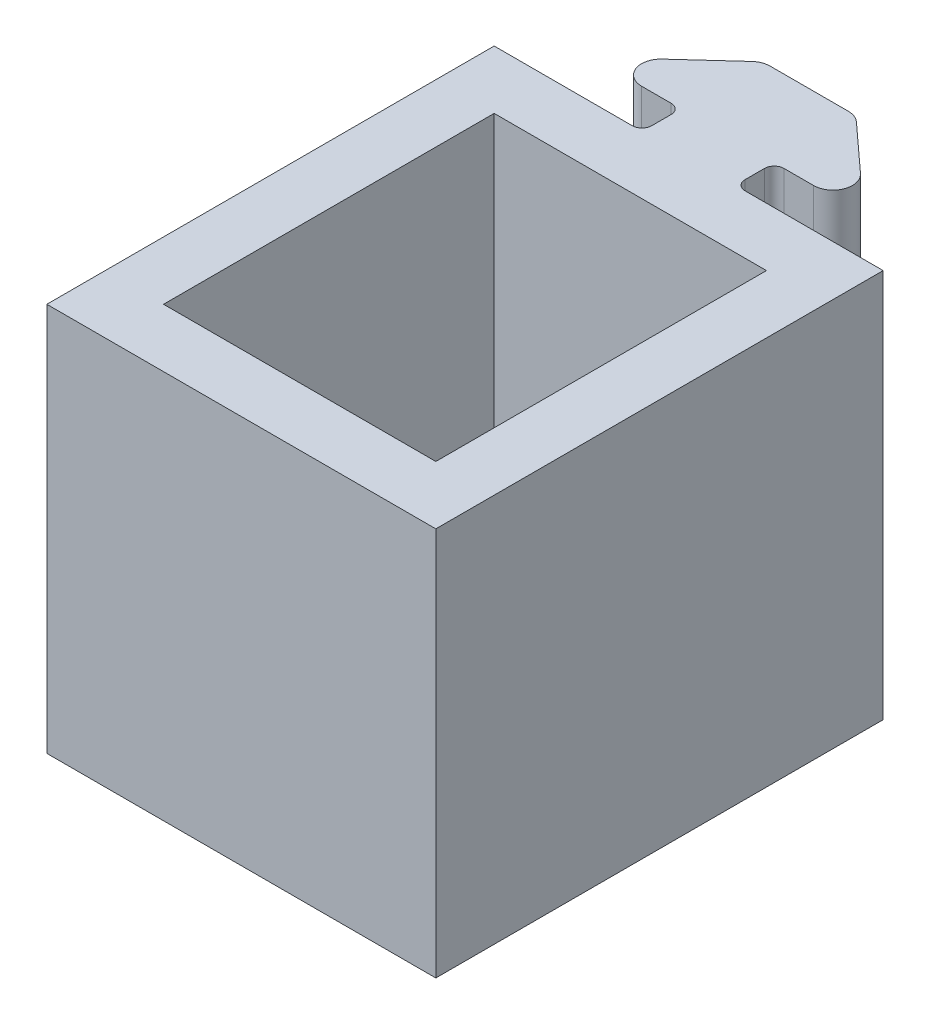
from build123d import *

# Parameters (mm, degrees)
BOSS_EXTRUDE1_DEPTH = 20
FILLET1_R           = 1
FILLET2_R           = 0.5
BOSS_EXTRUDE2_DEPTH = 20


with BuildPart() as part:
    # Sketch1 → Boss-Extrude1 (new body)
    with BuildSketch(Plane(origin=(0, 0, 0), x_dir=(1, 0, 0), z_dir=(0, 1, 0))):
        Polygon((-2.4, 4.581818182), (2.4, 4.581818182), (7, 0.381818182), (2.4, 0.381818182), (2.4, -1.618181818), (10, -1.618181818), (10, -4.618181818), (-10, -4.618181818), (-10, -1.618181818), (-2.4, -1.618181818), (-2.4, 0.381818182), (-7, 0.381818182), align=None)
    extrude(amount=BOSS_EXTRUDE1_DEPTH)

    # Fillet1
    fillet1_edges = [part.edges().sort_by_distance(p)[0] for p in [
        (7, 10, -0.381818182),
        (-7, 10, -0.381818182),
        (-2.4, 10, -4.581818182),
        (2.4, 10, -4.581818182),
    ]]
    fillet(fillet1_edges, radius=FILLET1_R)

    # Fillet2
    fillet2_edges = [part.edges().sort_by_distance(p)[0] for p in [
        (2.4, 10, -0.381818182),
        (2.4, 10, 1.618181818),
        (-2.4, 10, 1.618181818),
        (-2.4, 10, -0.381818182),
    ]]
    fillet(fillet2_edges, radius=FILLET2_R)

    # Sketch2 → Boss-Extrude2 (add)
    with BuildSketch(Plane(origin=(0, 20, 0), x_dir=(1, 0, 0), z_dir=(0, 1, 0))):
        Polygon((-7, -4.618181818), (-10, -4.618181818), (-10, -24.618181818), (10, -24.618181818), (10, -4.618181818), (7, -4.618181818), (7, -21.618181818), (-7, -21.618181818), align=None)
    extrude(amount=-BOSS_EXTRUDE2_DEPTH)


solid = part.part
